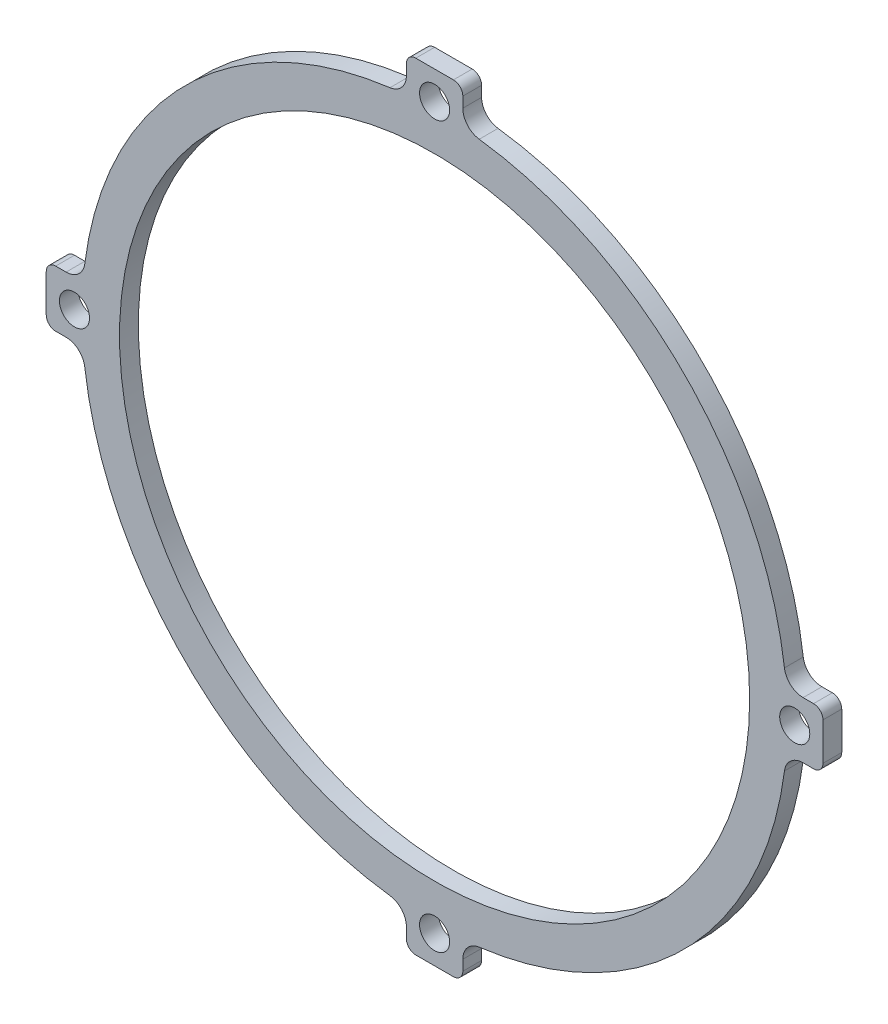
from build123d import *

# Parameters (mm, degrees)
SKETCH_1_R          = 1.6
EXTRUDE_1_DEPTH     = 2
SKETCH_3_R          = 4.5
SKETCH_3_R_2        = 1.25
CUT_EXTRUDE_1_DEPTH = 3
CUT_EXTRUDE_2_DEPTH = 3
FILLET_1_R          = 1
SKETCH_5_R          = 33.5
CUT_EXTRUDE_3_DEPTH = 3


with BuildPart() as part:
    # ｽｹｯﾁ1 → ﾎﾞｽ - 押し出し1 (new body)
    with BuildSketch(Plane.XY):
        with BuildLine():
            Line((-3, -39.182266397), (-3, -41.291643997))
            Line((-3, -41.291643997), (3, -41.291643997))
            Line((3, -41.291643997), (3, -39.182266397))
            ThreePointArc((3, -39.182266397), (3.498945518, -37.860587373), (4.746835443, -37.198354174))
            ThreePointArc((4.746835443, -37.198354174), (26.516504294, -26.516504294), (37.198354174, -4.746835443))
            ThreePointArc((37.198354174, -4.746835443), (37.860587373, -3.498945518), (39.182266397, -3))
            Line((39.182266397, -3), (41.291643997, -3))
            Line((41.291643997, -3), (41.291643997, 3))
            Line((41.291643997, 3), (39.182266397, 3))
            ThreePointArc((39.182266397, 3), (37.860587373, 3.498945518), (37.198354174, 4.746835443))
            ThreePointArc((37.198354174, 4.746835443), (26.516504294, 26.516504294), (4.746835443, 37.198354174))
            ThreePointArc((4.746835443, 37.198354174), (3.498945518, 37.860587373), (3, 39.182266397))
            Line((3, 39.182266397), (3, 41.291643997))
            Line((3, 41.291643997), (-3, 41.291643997))
            Line((-3, 41.291643997), (-3, 39.182266397))
            ThreePointArc((-3, 39.182266397), (-3.498945518, 37.860587373), (-4.746835443, 37.198354174))
            ThreePointArc((-4.746835443, 37.198354174), (-26.516504294, 26.516504294), (-37.198354174, 4.746835443))
            ThreePointArc((-37.198354174, 4.746835443), (-37.860587373, 3.498945518), (-39.182266397, 3))
            Line((-39.182266397, 3), (-41.291643997, 3))
            Line((-41.291643997, 3), (-41.291643997, -3))
            Line((-41.291643997, -3), (-39.182266397, -3))
            ThreePointArc((-39.182266397, -3), (-37.860587373, -3.498945518), (-37.198354174, -4.746835443))
            ThreePointArc((-37.198354174, -4.746835443), (-26.516504294, -26.516504294), (-4.746835443, -37.198354174))
            ThreePointArc((-4.746835443, -37.198354174), (-3.498945518, -37.860587373), (-3, -39.182266397))
        make_face()
        with Locations((-38.291643997, 0)):
            Circle(SKETCH_1_R, mode=Mode.SUBTRACT)
        with Locations((0, -38.291643997)):
            Circle(SKETCH_1_R, mode=Mode.SUBTRACT)
        with Locations((0, 38.291643997)):
            Circle(SKETCH_1_R, mode=Mode.SUBTRACT)
        with Locations((38.291643997, 0)):
            Circle(SKETCH_1_R, mode=Mode.SUBTRACT)
    extrude(amount=EXTRUDE_1_DEPTH)

    # ｽｹｯﾁ3 → ｶｯﾄ - 押し出し1 (cut, through all)
    with BuildSketch(Plane.XY.offset(2)):
        Circle(SKETCH_3_R)
        with Locations((0, 8.5)):
            Circle(SKETCH_3_R_2)
        with Locations((8.5, 0)):
            Circle(SKETCH_3_R_2)
        with Locations((0, -8.5)):
            Circle(SKETCH_3_R_2)
        with Locations((-8.5, 0)):
            Circle(SKETCH_3_R_2)
    extrude(amount=-CUT_EXTRUDE_1_DEPTH, mode=Mode.SUBTRACT)

    # ｽｹｯﾁ4 → ｶｯﾄ - 押し出し2 (cut, through all)
    with BuildSketch(Plane.XY.offset(2)):
        with BuildLine():
            Line((-3, 33.365401241), (-3, 12.1346611))
            ThreePointArc((-3, 12.1346611), (-8.838834765, 8.838834765), (-12.1346611, 3))
            Line((-12.1346611, 3), (-33.365401241, 3))
            ThreePointArc((-33.365401241, 3), (-23.68807717, 23.68807717), (-3, 33.365401241))
        make_face()
        with BuildLine():
            Line((3, 33.365401241), (3, 12.1346611))
            ThreePointArc((3, 12.1346611), (8.838834765, 8.838834765), (12.1346611, 3))
            Line((12.1346611, 3), (33.365401241, 3))
            ThreePointArc((33.365401241, 3), (23.68807717, 23.68807717), (3, 33.365401241))
        make_face()
        with BuildLine():
            Line((33.365401241, -3), (12.1346611, -3))
            ThreePointArc((12.1346611, -3), (8.838834765, -8.838834765), (3, -12.1346611))
            Line((3, -12.1346611), (3, -33.365401241))
            ThreePointArc((3, -33.365401241), (23.68807717, -23.68807717), (33.365401241, -3))
        make_face()
        with BuildLine():
            Line((-3, -33.365401241), (-3, -12.1346611))
            ThreePointArc((-3, -12.1346611), (-8.838834765, -8.838834765), (-12.1346611, -3))
            Line((-12.1346611, -3), (-33.365401241, -3))
            ThreePointArc((-33.365401241, -3), (-23.68807717, -23.68807717), (-3, -33.365401241))
        make_face()
    extrude(amount=-CUT_EXTRUDE_2_DEPTH, mode=Mode.SUBTRACT)

    # ﾌｨﾚｯﾄ1
    fillet_1_edges = [part.edges().sort_by_distance(p)[0] for p in [
        (-41.291643997, -3, 1),
        (-41.291643997, 3, 1),
        (-3, 41.291643997, 1),
        (3, 41.291643997, 1),
        (41.291643997, 3, 1),
        (41.291643997, -3, 1),
        (3, -41.291643997, 1),
        (-3, -41.291643997, 1),
    ]]
    fillet(fillet_1_edges, radius=FILLET_1_R)

    # ｽｹｯﾁ5 → ｶｯﾄ - 押し出し3 (cut, through all)
    with BuildSketch(Plane.XY.offset(2)):
        Circle(SKETCH_5_R)
    extrude(amount=-CUT_EXTRUDE_3_DEPTH, mode=Mode.SUBTRACT)


solid = part.part
